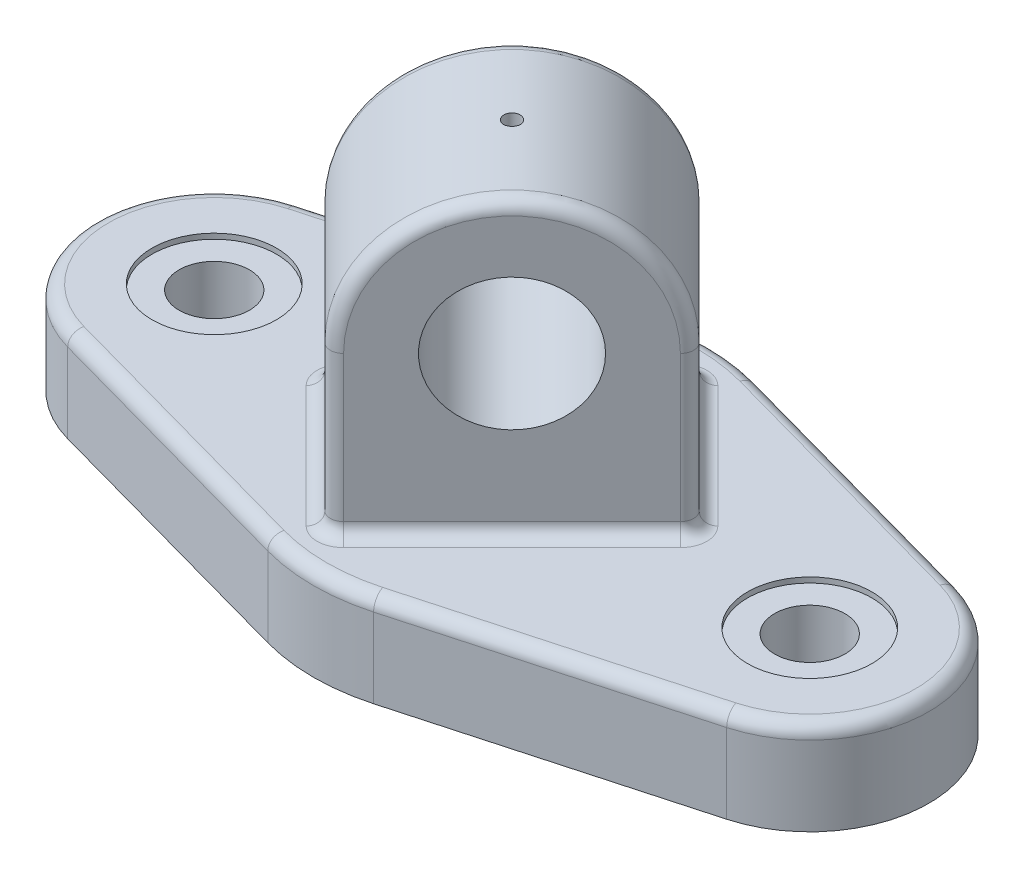
from build123d import *

# Parameters (mm, degrees)
BOSS_EXTRUDE1_DEPTH                                 = 17.78
CBORE_FOR_00_BINDING_HEAD_MACHINE_SCREW_D           = 13.4874
CBORE_FOR_00_BINDING_HEAD_MACHINE_SCREW_CBORE_D     = 23.876
CBORE_FOR_00_BINDING_HEAD_MACHINE_SCREW_CBORE_DEPTH = 1.016
SKETCH6_R                                           = 12.7
BOSS_EXTRUDE2_DEPTH                                 = 19.05
BOSS_EXTRUDE2_DEPTH_BACK                            = 19.05
F_1_8_0_125_DIAMETER_HOLE1_REACH                    = 117.235
F_1_8_0_125_DIAMETER_HOLE1_BORE_R                   = 1.5875
FILLET1_R                                           = 2.54


with BuildPart() as part:
    # Sketch1 → Boss-Extrude1 (new body)
    with BuildSketch(Plane(origin=(0, 0, 0), x_dir=(1, 0, 0), z_dir=(0, 1, 0))):
        with BuildLine():
            Line((-63.246, 22.032212417), (-10.16, 36.720354029))
            ThreePointArc((-10.16, 36.720354029), (0, 38.1), (10.16, 36.720354029))
            Line((10.16, 36.720354029), (63.246, 22.032212417))
            ThreePointArc((63.246, 22.032212417), (80.01, 0), (63.246, -22.032212417))
            Line((63.246, -22.032212417), (10.16, -36.720354029))
            ThreePointArc((10.16, -36.720354029), (0, -38.1), (-10.16, -36.720354029))
            Line((-10.16, -36.720354029), (-63.246, -22.032212417))
            ThreePointArc((-63.246, -22.032212417), (-80.01, 0), (-63.246, 22.032212417))
        make_face()
    extrude(amount=BOSS_EXTRUDE1_DEPTH)

    # CBORE for _00 Binding Head Machine Screw (through all)
    with Locations(Plane(origin=(0, 17.78, 0), x_dir=(1, 0, 0), z_dir=(0, 1, 0))):
        with Locations((57.15, 0), (-57.15, 0)):
            CounterBoreHole(CBORE_FOR_00_BINDING_HEAD_MACHINE_SCREW_D / 2, CBORE_FOR_00_BINDING_HEAD_MACHINE_SCREW_CBORE_D / 2, CBORE_FOR_00_BINDING_HEAD_MACHINE_SCREW_CBORE_DEPTH)

    # Sketch6 → Boss-Extrude2 (add, two sides)
    with BuildSketch(Plane(origin=(0, 0, 0), x_dir=(0, -1, 0), z_dir=(0.7071067811865464, 0, 0.7071067811865488))) as boss_extrude2_sk:
        with BuildLine():
            Line((-48.26, -25.4), (-17.78, -25.4))
            Line((-17.78, -25.4), (-17.78, 25.4))
            Line((-17.78, 25.4), (-48.26, 25.4))
            ThreePointArc((-48.26, 25.4), (-73.66, 0), (-48.26, -25.4))
        make_face()
        with Locations(Location((-48.26, 0, 0), (0, 0, 90))):
            Circle(SKETCH6_R, mode=Mode.SUBTRACT)
    extrude(amount=BOSS_EXTRUDE2_DEPTH)
    extrude(boss_extrude2_sk.sketch, amount=-BOSS_EXTRUDE2_DEPTH_BACK)

    # 1_8 _0.125_ Diameter Hole1 bore (on position points) → 1_8 _0.125_ Diameter Hole1 (cut, up to next)
    with BuildSketch(Plane.ZX.offset(73.66), mode=Mode.PRIVATE) as f_1_8_0_125_diameter_hole1_sk1:
        Circle(F_1_8_0_125_DIAMETER_HOLE1_BORE_R)
    f_1_8_0_125_diameter_hole1_tool1 = extrude(f_1_8_0_125_diameter_hole1_sk1.sketch, amount=-F_1_8_0_125_DIAMETER_HOLE1_REACH, mode=Mode.PRIVATE) & part.part
    add(f_1_8_0_125_diameter_hole1_tool1.solids().sort_by_distance((0, 73.66, 0))[0], mode=Mode.SUBTRACT)

    # Fillet1
    fillet1_edges = [part.edges().sort_by_distance(p)[0] for p in [
        (-80.01, 17.78, 0),
        (-36.703, 17.78, 29.376283223),
        (0, 17.78, 38.1),
        (36.703, 17.78, 29.376283223),
        (80.01, 17.78, 0),
        (36.703, 17.78, -29.376283223),
        (-13.470384182, 73.66, -13.470384182),
        (4.490128061, 33.02, -31.430896424),
        (0, 17.78, -38.1),
        (17.960512242, 17.78, -17.960512242),
        (-13.470384182, 17.78, -13.470384182),
        (-17.960512242, 17.78, 17.960512242),
        (-31.430896424, 33.02, 4.490128061),
        (13.470384182, 73.66, 13.470384182),
        (-4.490128061, 33.02, 31.430896424),
        (13.470384182, 17.78, 13.470384182),
        (31.430896424, 33.02, -4.490128061),
        (-36.703, 17.78, -29.376283223),
    ]]
    fillet(fillet1_edges, radius=FILLET1_R)


solid = part.part
